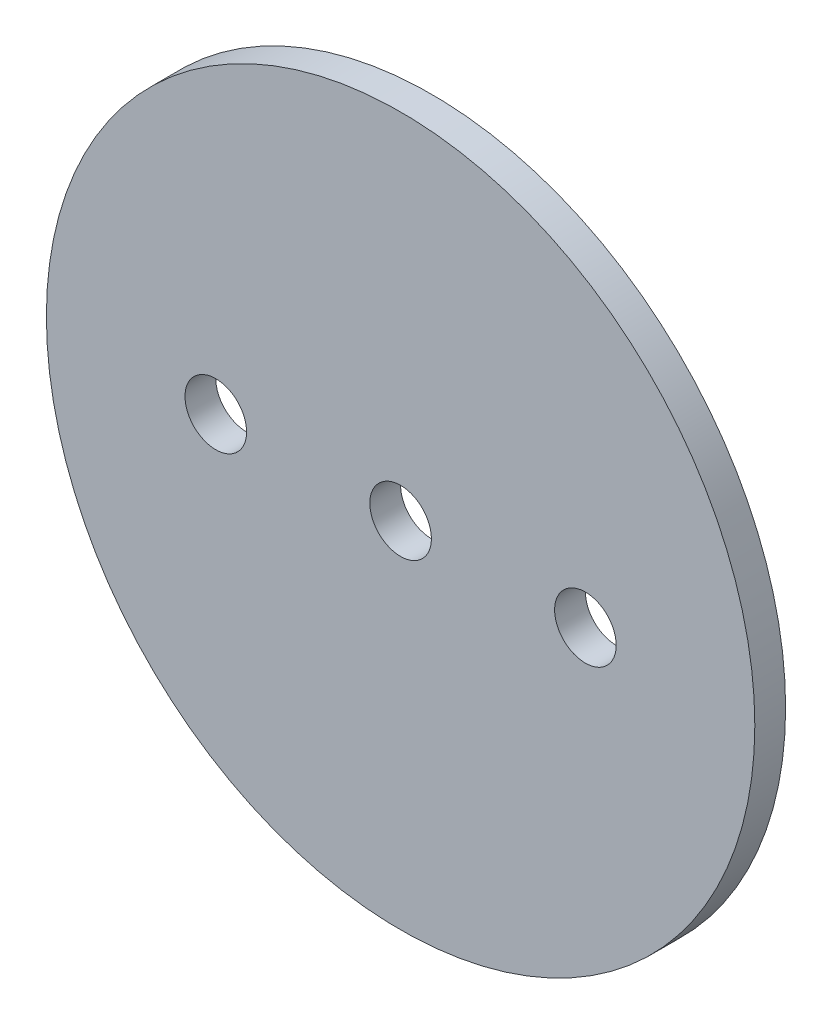
from build123d import *

# Parameters (mm, degrees)
SKETCH1_R                   = 36.5125
BOSS_EXTRUDE1_DEPTH         = 1.5875
F_1_4_0_25_DIAMETER_HOLE1_D = 6.35


with BuildPart() as part:
    # Sketch1 → Boss-Extrude1 (new body, symmetric)
    with BuildSketch(Plane.XY):
        Circle(SKETCH1_R)
    extrude(amount=BOSS_EXTRUDE1_DEPTH, both=True)

    # 1/4 (0.25) Diameter Hole1 (through all)
    with Locations(Plane.XY.offset(1.5875)):
        with Locations((-19.05, 0), (0, 0), (19.05, 0)):
            Hole(F_1_4_0_25_DIAMETER_HOLE1_D / 2)


solid = part.part
